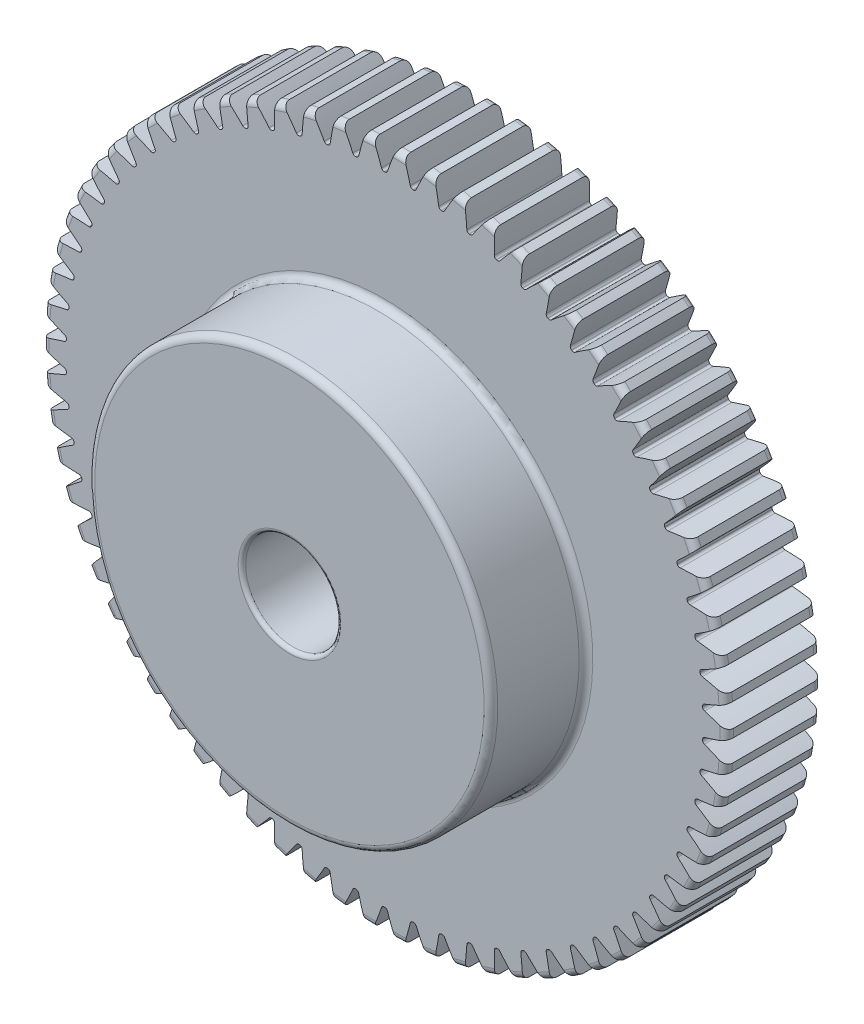
from build123d import *

# Parameters (mm, degrees)
FILLET2_R          = 0.9144
CUT_EXTRUDE2_DEPTH = 13.7
CIRPATTERN1_COUNT  = 70
FILLET3_R          = 0.508
SKETCH8_W          = 3.302
SKETCH8_H          = 3.302
CUT_EXTRUDE3_DEPTH = 12.7


with BuildPart() as part:
    # Sketch4 → Revolve1 (revolve)
    with BuildSketch(Plane(origin=(0, 0, 0), x_dir=(0, 0, -1), z_dir=(1, 0, 0))):
        Polygon((-25.4, 6.35), (-25.4, 26.924), (-12.7, 26.924), (-12.7, 45.72), (0, 45.72), (0, 6.35), align=None)
    revolve(axis=Axis((0, 0, 12.7), (0, 0, 1)))

    # Fillet2
    fillet2_edges = [part.edges().sort_by_distance(p)[0] for p in [
        (0, -45.72, 0),
        (0, -45.72, 12.7),
        (0, -26.924, 12.7),
        (0, -26.924, 25.4),
    ]]
    fillet(fillet2_edges, radius=FILLET2_R)

    # Sketch7 → Cut-Extrude2 (cut, through all)
    with BuildSketch(Plane.XY.offset(12.7)):
        with BuildLine():
            ThreePointArc((-0.035776995, 42.544984957), (0, 42.545), (0.035776995, 42.544984957))
            ThreePointArc((0.035776995, 42.544984957), (0.257128983, 42.615646356), (0.396284661, 42.80172546))
            ThreePointArc((0.396284661, 42.80172546), (0.927425025, 44.258110998), (1.50902682, 45.695089868))
            ThreePointArc((1.50902682, 45.695089868), (0, 45.72), (-1.50902682, 45.695089868))
            ThreePointArc((-1.50902682, 45.695089868), (-0.927425025, 44.258110998), (-0.396284661, 42.80172546))
            ThreePointArc((-0.396284661, 42.80172546), (-0.257128983, 42.615646356), (-0.035776995, 42.544984957))
        make_face()
    cut_extrude2 = extrude(amount=-CUT_EXTRUDE2_DEPTH, mode=Mode.SUBTRACT)

    # CirPattern1: Cut-Extrude2 ×70 about axis
    cirpattern1_axis = Axis((0, 0, 0), (0, 0, 1))
    for i in range(1, CIRPATTERN1_COUNT):
        add(cut_extrude2.rotate(cirpattern1_axis, i * 360 / CIRPATTERN1_COUNT), mode=Mode.SUBTRACT)

    # Fillet3
    fillet3_edges = [part.edges().sort_by_distance(p)[0] for p in [
        (0, -6.35, 0),
        (0, -6.35, 25.4),
    ]]
    fillet(fillet3_edges, radius=FILLET3_R)

    # Sketch8 → Cut-Extrude3 (cut)
    with BuildSketch(Plane(origin=(0, 0, 0), x_dir=(-1, 0, 0), z_dir=(0, 0, -1))):
        with Locations((0, 6.131614714)):
            Rectangle(SKETCH8_W, SKETCH8_H)
    extrude(amount=-CUT_EXTRUDE3_DEPTH, mode=Mode.SUBTRACT)


solid = part.part
